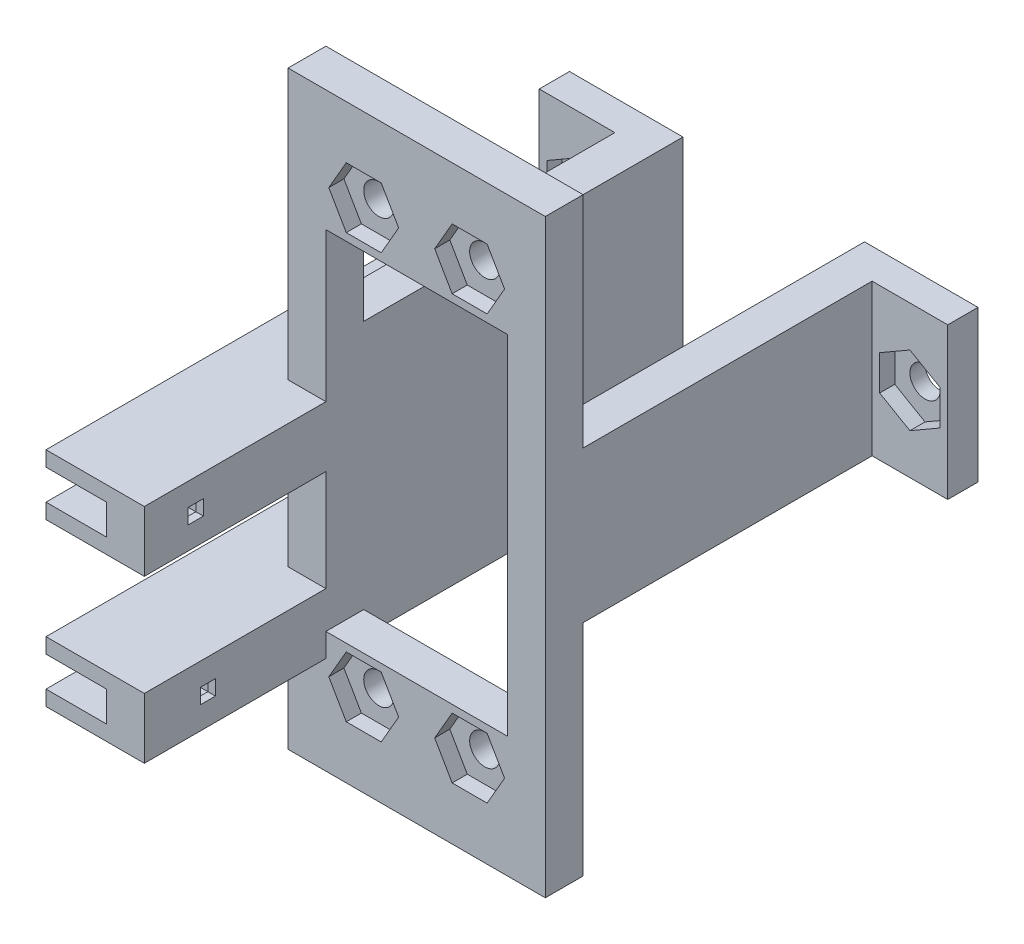
from build123d import *

# Parameters (mm, degrees)
SKETCH1_W                     = 17
SKETCH1_H                     = 39
SKETCH1_R                     = 1
SKETCH1_W_2                   = 12
SKETCH1_H_2                   = 23
SERVOBRACKET_DEPTH            = 2.5
SKETCH1_5_W                   = 2.5
SKETCH1_5_H                   = 10
SUPPORTLEGS_DEPTH             = 21.1
SKETCH2_W                     = 2
SKETCH2_H                     = 10
SUPPORTFOOT_DEPTH             = 5
BASEBOLTHOLE_START            = -3
SKETCH3_R                     = 1
BASEBOLTHOLE_DEPTH            = 25.6
SERVONUTSLOTS_DEPTH           = 1
BASENUTSLOTS_DEPTH            = 1
SKETCH6_W                     = 2.5
SKETCH6_H                     = 4
TUBEHOLDERBASE_DEPTH          = 12
SKETCH7_W                     = 4
SKETCH7_H                     = 1
TUBEHOLDERSTIFFENERRIBS_DEPTH = 30.6
SKETCH8_W                     = 1
SKETCH8_H                     = 1
SKETCH8_W_2                   = 1.5
SKETCH8_H_2                   = 1.5
TUBECLIPENTRANCES_DEPTH       = 2
SKETCH8_3_W                   = 1
SKETCH8_3_H                   = 1
CABLEEXITS_DEPTH              = 2.5
SKETCH9_W                     = 1.5
SKETCH9_H                     = 1.5
TUBECLIPLOCKSLOT_DEPTH        = 0.6
SKETCH10_W                    = 1.5
SKETCH10_H                    = 1.5
TUBECLIPLOCKSLOT2_DEPTH       = 0.6
SUPPORTLEGEXTENSION_DEPTH     = 8.05
SKETCH8_4_W                   = 0.2
SKETCH8_4_H                   = 1.5
TUBECLIPLOCKCLEARANCE_DEPTH   = 0.5


with BuildPart() as part:
    # Sketch1 → ServoBracket (new body)
    with BuildSketch(Plane.XY):
        with Locations((0, 19.5)):
            Rectangle(SKETCH1_W, SKETCH1_H)
        with Locations((-3.5, 33.5)):
            Circle(SKETCH1_R, mode=Mode.SUBTRACT)
        with Locations((-3.5, 5.5)):
            Circle(SKETCH1_R, mode=Mode.SUBTRACT)
        with Locations((3.5, 5.5)):
            Circle(SKETCH1_R, mode=Mode.SUBTRACT)
        with Locations((3.5, 33.5)):
            Circle(SKETCH1_R, mode=Mode.SUBTRACT)
        with Locations((0, 19.5)):
            Rectangle(SKETCH1_W_2, SKETCH1_H_2, mode=Mode.SUBTRACT)
    extrude(amount=SERVOBRACKET_DEPTH)

    # Sketch1_5 → SupportLegs (add)
    with BuildSketch(Plane.XY):
        with Locations((-7.25, 19.5)):
            Rectangle(SKETCH1_5_W, SKETCH1_5_H)
        with Locations((7.25, 19.5)):
            Rectangle(SKETCH1_5_W, SKETCH1_5_H)
    extrude(amount=-SUPPORTLEGS_DEPTH)

    # Sketch2 → SupportFoot (add)
    with BuildSketch(Plane.ZY.offset(8.5)):
        with Locations((-20.1, 19.5)):
            Rectangle(SKETCH2_W, SKETCH2_H)
    supportfoot = extrude(amount=SUPPORTFOOT_DEPTH)

    # Sketch3 → BaseBoltHole (cut)
    with BuildSketch(Plane.XY.offset(-19.1).offset(BASEBOLTHOLE_START)):
        with Locations((-11, 19.5)):
            Circle(SKETCH3_R)
    basebolthole = extrude(amount=BASEBOLTHOLE_DEPTH, mode=Mode.SUBTRACT)

    # SupportFoot2: SupportFoot, BaseBoltHole across plane
    add(supportfoot.mirror(Plane(origin=(0, 0, 0), x_dir=(0, 0, 1), z_dir=(1, 0, 0))))
    add(basebolthole.mirror(Plane(origin=(0, 0, 0), x_dir=(0, 0, 1), z_dir=(1, 0, 0))), mode=Mode.SUBTRACT)

    # Sketch4 → ServoNutSlots (cut)
    with BuildSketch(Plane.XY.offset(2.5)):
        Polygon((-4.654700538, 7.5), (-2.345299462, 7.5), (-1.190598923, 5.5), (-2.345299462, 3.5), (-4.654700538, 3.5), (-5.809401077, 5.5), align=None)
        Polygon((-1.190598923, 33.5), (-2.345299462, 35.5), (-4.654700538, 35.5), (-5.809401077, 33.5), (-4.654700538, 31.5), (-2.345299462, 31.5), align=None)
        Polygon((2.345299462, 31.5), (1.190598923, 33.5), (2.345299462, 35.5), (4.654700538, 35.5), (5.809401077, 33.5), (4.654700538, 31.5), align=None)
        Polygon((4.654700538, 7.5), (2.345299462, 7.5), (1.190598923, 5.5), (2.345299462, 3.5), (4.654700538, 3.5), (5.809401077, 5.5), align=None)
    extrude(amount=-SERVONUTSLOTS_DEPTH, mode=Mode.SUBTRACT)

    # Sketch5 → BaseNutSlots (cut)
    with BuildSketch(Plane.XY.offset(-19.1)):
        Polygon((-11, 21.809401077), (-13, 20.654700538), (-13, 18.345299462), (-11, 17.190598923), (-9, 18.345299462), (-9, 20.654700538), align=None)
        Polygon((11, 21.809401077), (9, 20.654700538), (9, 18.345299462), (11, 17.190598923), (13, 18.345299462), (13, 20.654700538), align=None)
    extrude(amount=-BASENUTSLOTS_DEPTH, mode=Mode.SUBTRACT)

    # Sketch6 → TubeHolderBase (add)
    with BuildSketch(Plane.XY.offset(2.5)):
        with Locations((-7.25, 19.15)):
            Rectangle(SKETCH6_W, SKETCH6_H)
    tubeholderbase = extrude(amount=TUBEHOLDERBASE_DEPTH)

    # Sketch7 → TubeHolderStiffenerRibs (add)
    with BuildSketch(Plane.XY.offset(14.5)):
        with Locations((-10.5, 20.65)):
            Rectangle(SKETCH7_W, SKETCH7_H)
        with Locations((-10.5, 17.65)):
            Rectangle(SKETCH7_W, SKETCH7_H)
    tubeholderstiffenerribs = extrude(amount=-TUBEHOLDERSTIFFENERRIBS_DEPTH)

    # TubeHolder2: TubeHolderBase, TubeHolderStiffenerRibs across plane
    add(tubeholderbase.mirror(Plane.ZX.offset(13.8)))
    add(tubeholderstiffenerribs.mirror(Plane.ZX.offset(13.8)))

    # Sketch8 → TubeClipEntrances (cut)
    with BuildSketch(Plane.ZY.offset(8.5)):
        with Locations((11.1, 19.15)):
            Rectangle(SKETCH8_W, SKETCH8_H)
        with Locations((11.1, 19.15)):
            Rectangle(SKETCH8_W_2, SKETCH8_H_2)
        with Locations((11.1, 19.15)):
            Rectangle(SKETCH8_W, SKETCH8_H, mode=Mode.SUBTRACT)
        with Locations((10.3, 8.45)):
            Rectangle(SKETCH8_W, SKETCH8_H)
        with Locations((10.3, 8.45)):
            Rectangle(SKETCH8_W_2, SKETCH8_H_2)
        with Locations((10.3, 8.45)):
            Rectangle(SKETCH8_W, SKETCH8_H, mode=Mode.SUBTRACT)
    extrude(amount=-TUBECLIPENTRANCES_DEPTH, mode=Mode.SUBTRACT)

    # Sketch8_3 → CableExits (cut)
    with BuildSketch(Plane.ZY.offset(8.5)):
        with Locations((11.1, 19.15)):
            Rectangle(SKETCH8_3_W, SKETCH8_3_H)
        with Locations((10.3, 8.45)):
            Rectangle(SKETCH8_3_W, SKETCH8_3_H)
    extrude(amount=-CABLEEXITS_DEPTH, mode=Mode.SUBTRACT)

    # Sketch9 → TubeClipLockSlot (cut)
    with BuildSketch(Plane(origin=(0, 0, 11.85), x_dir=(-1, 0, 0), z_dir=(0, 0, -1))):
        with Locations((7.25, 19.15)):
            Rectangle(SKETCH9_W, SKETCH9_H)
    extrude(amount=-TUBECLIPLOCKSLOT_DEPTH, mode=Mode.SUBTRACT)

    # Sketch10 → TubeClipLockSlot2 (cut)
    with BuildSketch(Plane(origin=(0, 0, 11.05), x_dir=(-1, 0, 0), z_dir=(0, 0, -1))):
        with Locations((7.25, 8.45)):
            Rectangle(SKETCH10_W, SKETCH10_H)
    extrude(amount=-TUBECLIPLOCKSLOT2_DEPTH, mode=Mode.SUBTRACT)

    # Sketch11 → SupportLegExtension (add)
    with BuildSketch(Plane.XZ.offset(-14.5)):
        Polygon((-6, 0), (-8.5, 0), (-8.5, -19.1), (-13.5, -19.1), (-13.5, -21.1), (-6, -21.1), align=None)
    extrude(amount=SUPPORTLEGEXTENSION_DEPTH)

    # Sketch8_4 → TubeClipLockClearance (cut)
    with BuildSketch(Plane.ZY.offset(8.5)):
        with Locations((11.15, 8.45)):
            Rectangle(SKETCH8_4_W, SKETCH8_4_H)
        with Locations((11.95, 19.15)):
            Rectangle(SKETCH8_4_W, SKETCH8_4_H)
    extrude(amount=-TUBECLIPLOCKCLEARANCE_DEPTH, mode=Mode.SUBTRACT)


solid = part.part
